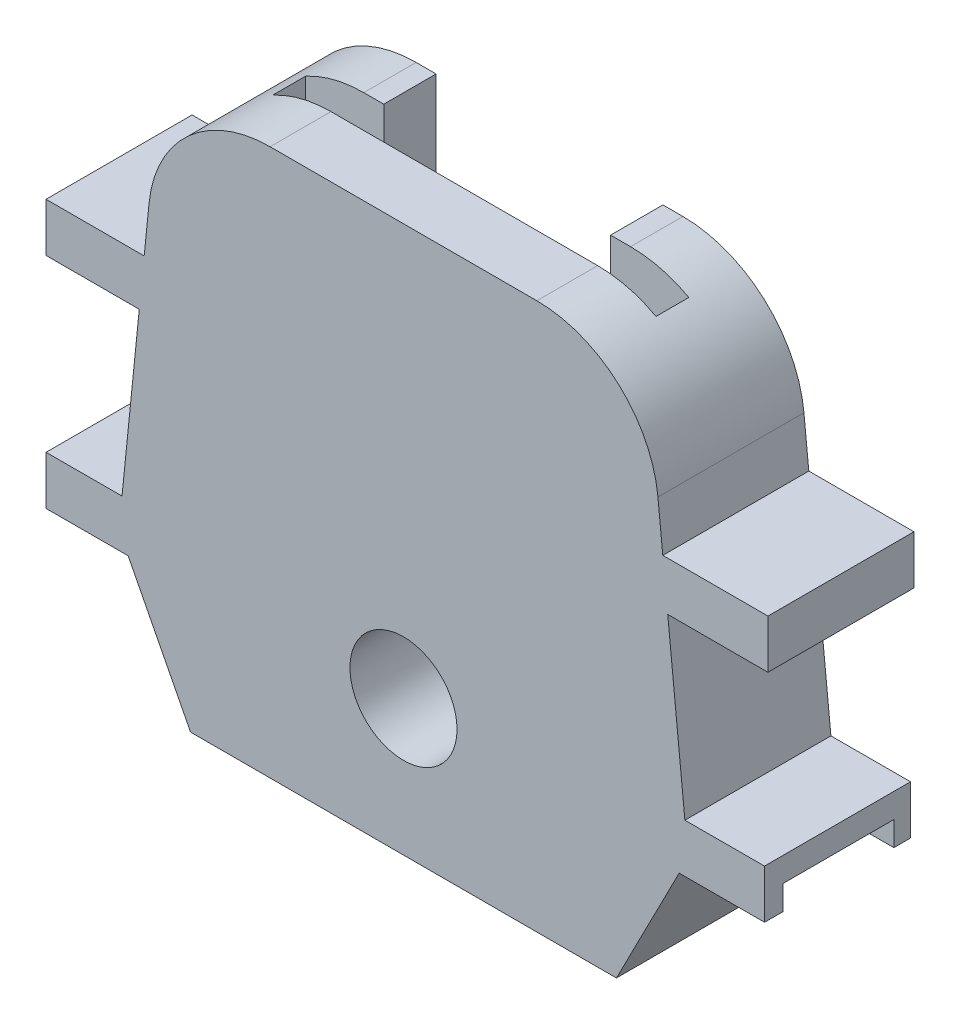
from build123d import *

# Parameters (mm, degrees)
SKETCH2_R           = 4.4
BOSS_EXTRUDE1_DEPTH = 12
CUT_EXTRUDE1_DEPTH  = 2
SKETCH4_W           = 31.5
SKETCH4_H           = 26.5
CUT_EXTRUDE2_DEPTH  = 2.7
CUT_EXTRUDE3_REACH  = 14
SKETCH5_W           = 18.640557444
SKETCH5_H           = 25


with BuildPart() as part:
    # Sketch2 → Boss-Extrude1 (new body)
    with BuildSketch(Plane.XY):
        with BuildLine():
            Line((-26.652708458, 24.799544054), (-27.052594325, 20.847218157))
            Line((-27.052594325, 20.847218157), (-35.117996865, 20.847218157))
            Line((-35.117996865, 20.847218157), (-35.117996865, 16.847218157))
            Line((-35.117996865, 16.847218157), (-27.457303732, 16.847218157))
            Line((-27.457303732, 16.847218157), (-28.873786654, 2.847218157))
            Line((-28.873786654, 2.847218157), (-35.117996865, 2.839337807))
            Line((-35.117996865, 2.839337807), (-35.112948764, -1.160662193))
            Line((-35.112948764, -1.160662193), (-28.37093921, -1.152153607))
            Line((-28.37093921, -1.152153607), (-23.24278353, -11.137592085))
            Line((-23.24278353, -11.137592085), (11.75721647, -11.137592085))
            Line((11.75721647, -11.137592085), (16.91451101, -1.09500223))
            Line((16.91451101, -1.09500223), (23.93161739, -1.086146466))
            Line((23.93161739, -1.086146466), (23.92656929, 2.913853534))
            Line((23.92656929, 2.913853534), (17.382313229, 2.905594519))
            Line((17.382313229, 2.905594519), (15.971736672, 16.847218157))
            Line((15.971736672, 16.847218157), (24.207665477, 16.847218157))
            Line((24.207665477, 16.847218157), (24.207665477, 20.847218157))
            Line((24.207665477, 20.847218157), (15.567027266, 20.847218157))
            Line((15.567027266, 20.847218157), (15.167141399, 24.799544054))
            ThreePointArc((15.167141399, 24.799544054), (11.923667067, 31.21134436), (5.217936029, 33.792909804))
            Line((5.217936029, 33.792909804), (-16.703503089, 33.792909804))
            ThreePointArc((-16.703503089, 33.792909804), (-23.409234126, 31.21134436), (-26.652708458, 24.799544054))
        make_face()
        with Locations((-5.74278353, 0)):
            Circle(SKETCH2_R, mode=Mode.SUBTRACT)
    extrude(amount=BOSS_EXTRUDE1_DEPTH)

    # Sketch3 → Cut-Extrude1 (cut)
    with BuildSketch(Plane(origin=(0.001408858, -1.116346991, 0), x_dir=(0.999999204, 0.001262024, 0), z_dir=(0.001262024, -0.999999204, 0))):
        Polygon((-35.114385586, 10.5), (-29.114385586, 10.5), (-29.114385586, 8.5), (-29.114385586, 3.523848556), (-29.114385586, 1.461924081), (-35.114385586, 1.461924081), (-35.114385586, 3.523848556), (-35.114385586, 8.5), align=None)
        Polygon((17.930227589, 10.5), (23.930227589, 10.5), (23.930227589, 8.5), (23.930227589, 3.438075525), (23.930227589, 1.376151049), (17.930227589, 1.376151049), (17.930227589, 3.438075525), (17.930227589, 8.5), align=None)
    extrude(amount=-CUT_EXTRUDE1_DEPTH, mode=Mode.SUBTRACT)

    # Sketch4 → Cut-Extrude2 (cut)
    with BuildSketch(Plane.XY.offset(7)):
        with Locations((-5.74278353, 20.542909804)):
            Rectangle(SKETCH4_W, SKETCH4_H)
    extrude(amount=-CUT_EXTRUDE2_DEPTH, mode=Mode.SUBTRACT)

    # Sketch5 → Cut-Extrude3 (cut, up to next)
    with BuildSketch(Plane(origin=(0, 0, 0), x_dir=(-1, 0, 0), z_dir=(0, 0, -1)), mode=Mode.PRIVATE) as cut_extrude3_sk1:
        with Locations((5.74278353, 21.292909804)):
            Rectangle(SKETCH5_W, SKETCH5_H)
    cut_extrude3_tool1 = extrude(cut_extrude3_sk1.sketch, amount=-CUT_EXTRUDE3_REACH, mode=Mode.PRIVATE) & part.part
    add(cut_extrude3_tool1.solids().sort_by_distance((-5.742784, 21.29291, 0))[0], mode=Mode.SUBTRACT)


solid = part.part
